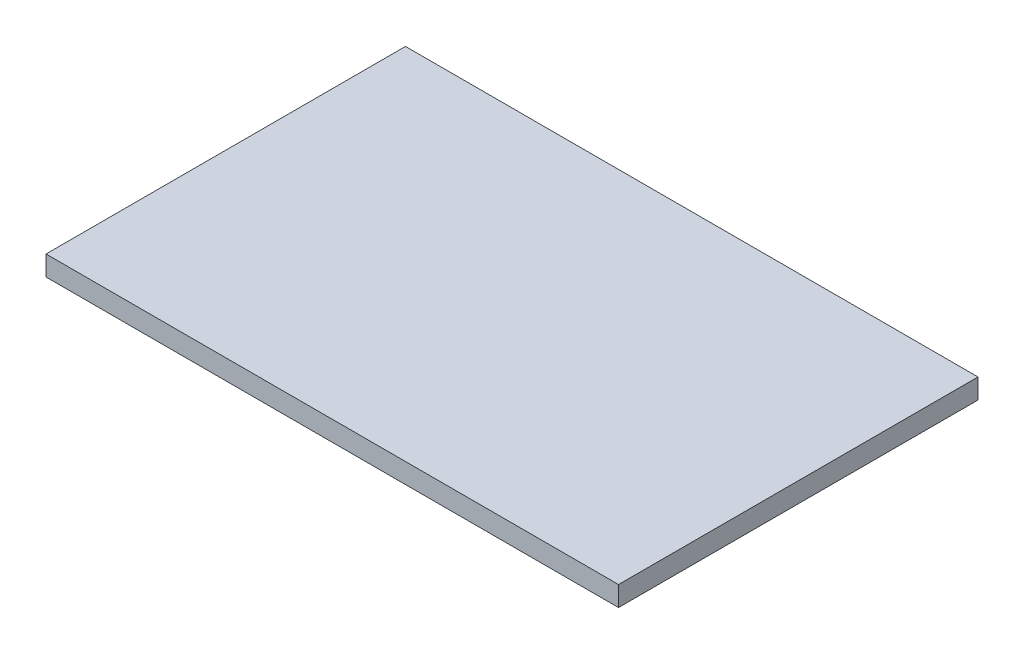
from build123d import *

# Parameters (mm, degrees)
ESBO_O1_W                = 4300
ESBO_O1_H                = 150
RESSALTO_EXTRUS_O1_DEPTH = 2700


with BuildPart() as part:
    # Esboço1 → Ressalto-extrusão1 (new body)
    with BuildSketch(Plane.XY):
        with Locations((2150, 75)):
            Rectangle(ESBO_O1_W, ESBO_O1_H)
    extrude(amount=RESSALTO_EXTRUS_O1_DEPTH)


solid = part.part
